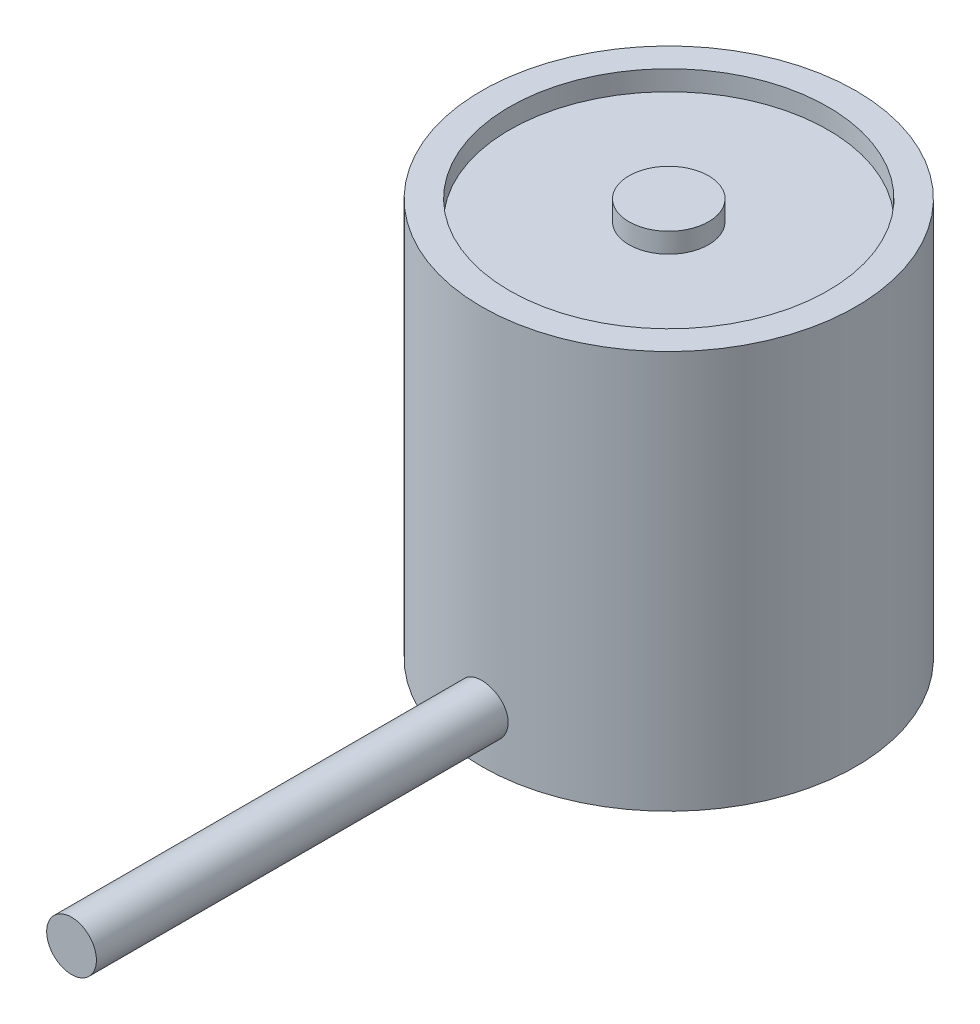
from build123d import *

# Parameters (mm, degrees)
SKETCH1_R           = 11.938
BOSS_EXTRUDE1_DEPTH = 25.4
SKETCH2_R           = 10.16
SKETCH2_R_2         = 2.54
CUT_EXTRUDE1_DEPTH  = 1.27
SKETCH3_R           = 1.5875
BOSS_EXTRUDE2_DEPTH = 38.1


with BuildPart() as part:
    # Sketch1 → Boss-Extrude1 (new body)
    with BuildSketch(Plane(origin=(0, 0, 0), x_dir=(1, 0, 0), z_dir=(0, 1, 0))):
        Circle(SKETCH1_R)
    extrude(amount=BOSS_EXTRUDE1_DEPTH)

    # Sketch2 → Cut-Extrude1 (cut)
    with BuildSketch(Plane(origin=(0, 25.4, 0), x_dir=(1, 0, 0), z_dir=(0, 1, 0))):
        Circle(SKETCH2_R)
        Circle(SKETCH2_R_2, mode=Mode.SUBTRACT)
    extrude(amount=-CUT_EXTRUDE1_DEPTH, mode=Mode.SUBTRACT)

    # Sketch3 → Boss-Extrude2 (add)
    with BuildSketch(Plane.XY):
        with Locations((0, 3.175)):
            Circle(SKETCH3_R)
    extrude(amount=BOSS_EXTRUDE2_DEPTH)


solid = part.part
